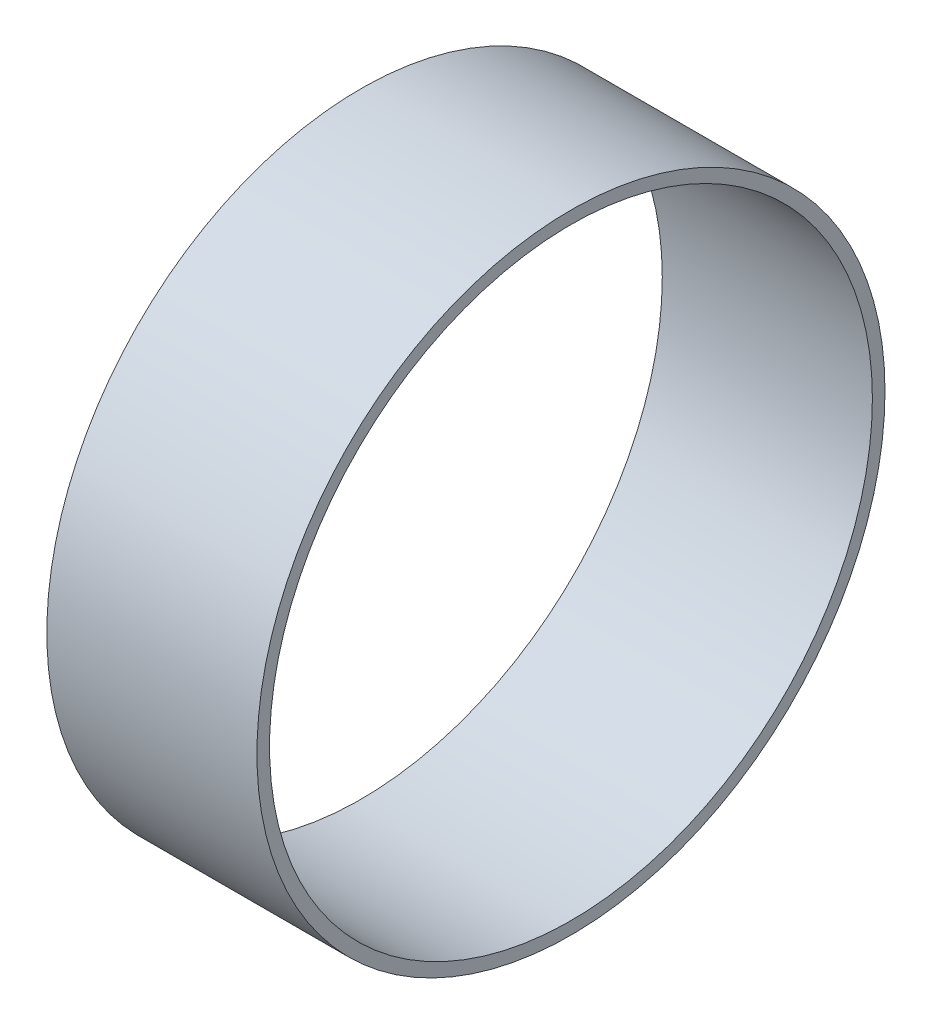
from build123d import *

# Parameters (mm, degrees)
SKETCH1_R           = 28.4734
SKETCH1_R_2         = 27.3304
BOSS_EXTRUDE1_DEPTH = 9.525


with BuildPart() as part:
    # Sketch1 → Boss-Extrude1 (new body, symmetric)
    with BuildSketch(Plane(origin=(0, 0, 0), x_dir=(0, 0, -1), z_dir=(1, 0, 0))):
        Circle(SKETCH1_R)
        Circle(SKETCH1_R_2, mode=Mode.SUBTRACT)
    extrude(amount=BOSS_EXTRUDE1_DEPTH, both=True)


solid = part.part
